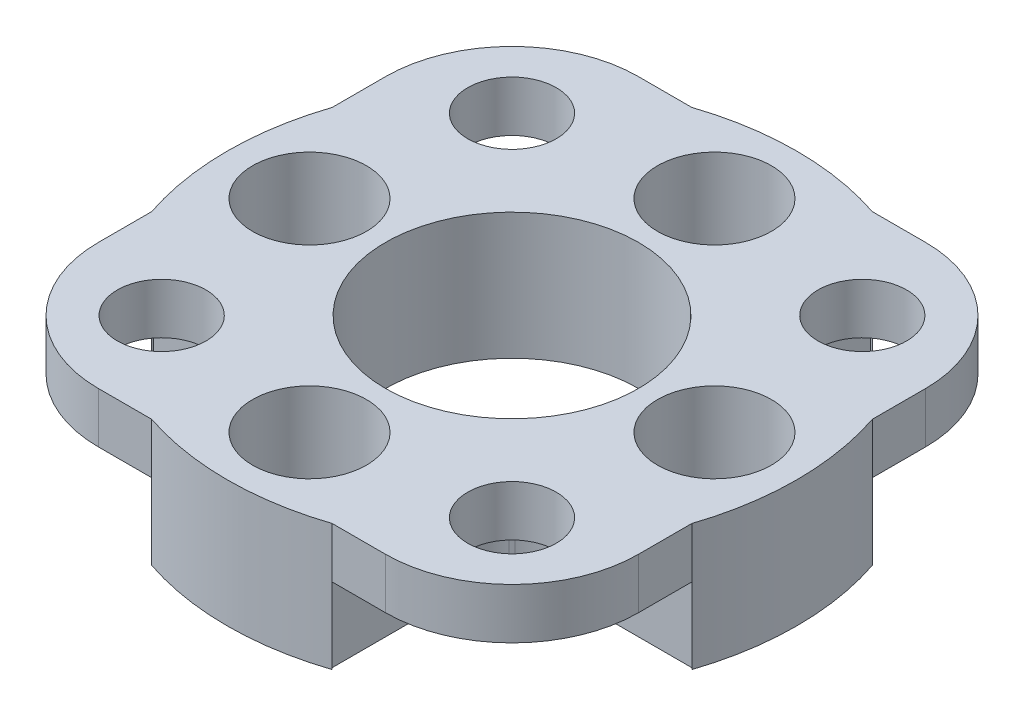
from build123d import *

# Parameters (mm, degrees)
ESQUISSE1_R                                     = 11.25
BOSS_EXTRU_1_DEPTH                              = 2
ESQUISSE8_R                                     = 11.25
BOSS_EXTRU_2_DEPTH                              = 3
ESQUISSE15_W                                    = 21.34
ESQUISSE15_H                                    = 21.34
BOSS_EXTRU_3_DEPTH                              = 2
ESQUISSE14_R                                    = 5
ENL_V_MAT_EXTRU_3_DEPTH                         = 6
D_GAGEMENT_M21_D                                = 3.5
ENL_V_MAT_EXTRU_11_DEPTH                        = 3
CONG_1_R                                        = 5
ESQUISSE20_R                                    = 6.103277808
ESQUISSE20_R_2                                  = 5
BOSS_EXTRU_5_DEPTH                              = 3
CONG_3_R                                        = 2.5
CHAMBRAGE_POUR_VIS_T_TE_CYLINDRIQUE_D           = 2.5
CHAMBRAGE_POUR_VIS_T_TE_CYLINDRIQUE_CBORE_D     = 4.5
CHAMBRAGE_POUR_VIS_T_TE_CYLINDRIQUE_CBORE_DEPTH = 3.3


with BuildPart() as part:
    # Esquisse1 → Boss.-Extru.1 (new body)
    with BuildSketch(Plane(origin=(0, 0, 0), x_dir=(1, 0, 0), z_dir=(0, 1, 0))):
        Circle(ESQUISSE1_R)
    extrude(amount=BOSS_EXTRU_1_DEPTH)

    # Esquisse8 → Boss.-Extru.2 (add)
    with BuildSketch(Plane.XZ):
        Circle(ESQUISSE8_R)
    extrude(amount=BOSS_EXTRU_2_DEPTH)

    # Esquisse15 → Boss.-Extru.3 (add)
    with BuildSketch(Plane(origin=(0, 2, 0), x_dir=(1, 0, 0), z_dir=(0, 1, 0))):
        Rectangle(ESQUISSE15_W, ESQUISSE15_H)
    extrude(amount=-BOSS_EXTRU_3_DEPTH)

    # Esquisse14 → Enlèv. mat.-Extru.3 (cut)
    with BuildSketch(Plane.XZ.offset(3)):
        Circle(ESQUISSE14_R)
    extrude(amount=-ENL_V_MAT_EXTRU_3_DEPTH, mode=Mode.SUBTRACT)

    # Dégagement M21 (through all)
    with Locations(Plane(origin=(0, 2, 0), x_dir=(1, 0, 0), z_dir=(0, 1, 0))):
        with Locations((6.92, -6.92), (-6.92, -6.92), (-6.92, 6.92), (6.92, 6.92)):
            Hole(D_GAGEMENT_M21_D / 2)

    # Esquisse18 → Enlèv. mat.-Extru.11 (cut)
    with BuildSketch(Plane.XZ):
        Polygon((-3.5, -10.67), (-3.5, -5), (3.5, -5), (3.5, -10.67), (10.67, -10.67), (10.67, -3.5), (5, -3.5), (5, 3.5), (10.67, 3.5), (10.67, 10.67), (3.5, 10.67), (3.5, 5), (-3.5, 5), (-3.5, 10.67), (-10.67, 10.67), (-10.67, 3.5), (-5, 3.5), (-5, -3.5), (-10.67, -3.5), (-10.67, -10.67), align=None)
    extrude(amount=ENL_V_MAT_EXTRU_11_DEPTH, mode=Mode.SUBTRACT)

    # Congé1
    cong_1_edges = [part.edges().sort_by_distance(p)[0] for p in [
        (-10.67, 1, 10.67),
        (-10.67, 1, -10.67),
        (10.67, 1, -10.67),
        (10.67, 1, 10.67),
    ]]
    fillet(cong_1_edges, radius=CONG_1_R)

    # Esquisse20 → Boss.-Extru.5 (add)
    with BuildSketch(Plane.XZ):
        Circle(ESQUISSE20_R)
        Circle(ESQUISSE20_R_2, mode=Mode.SUBTRACT)
    extrude(amount=BOSS_EXTRU_5_DEPTH)

    # Congé3
    cong_3_edges = [part.edges().sort_by_distance(p)[0] for p in [
        (-5, -1.5, 3.5),
        (-3.5, -1.5, -5),
        (5, -1.5, -3.5),
        (3.5, -1.5, 5),
        (-5, -1.5, -3.5),
        (3.5, -1.5, -5),
        (5, -1.5, 3.5),
        (-3.5, -1.5, 5),
    ]]
    fillet(cong_3_edges, radius=CONG_3_R)

    # Chambrage pour vis à tête cylindrique à 6 pans creux (ou vis CHC) M21 (through all)
    with Locations(Plane(origin=(0, 2, 0), x_dir=(1, 0, 0), z_dir=(0, 1, 0))):
        with Locations((-8, 0), (0, -8), (8, 0), (0, 8)):
            CounterBoreHole(CHAMBRAGE_POUR_VIS_T_TE_CYLINDRIQUE_D / 2, CHAMBRAGE_POUR_VIS_T_TE_CYLINDRIQUE_CBORE_D / 2, CHAMBRAGE_POUR_VIS_T_TE_CYLINDRIQUE_CBORE_DEPTH)


solid = part.part
